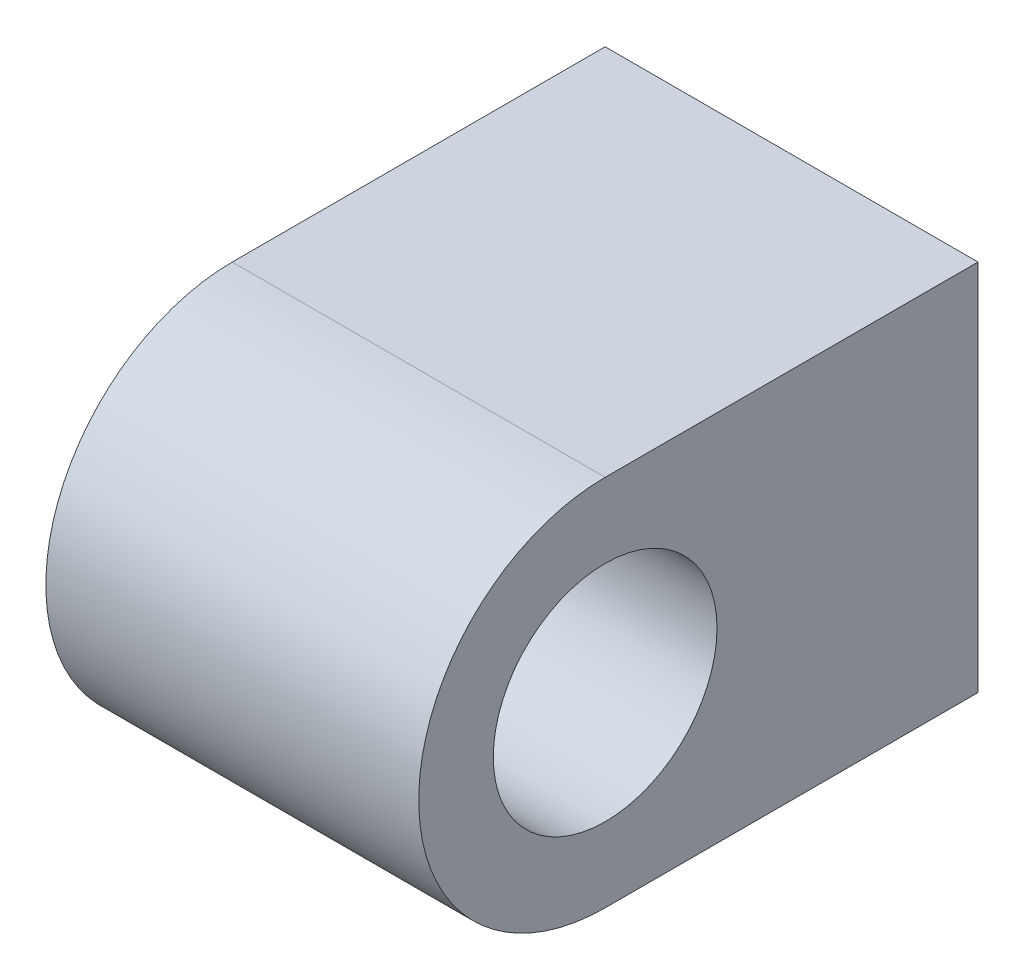
from build123d import *

# Parameters (mm, degrees)
ESQUISSE1_R        = 1.5
BOSS_EXTRU_1_DEPTH = 5


with BuildPart() as part:
    # Esquisse1 → Boss.-Extru.1 (new body)
    with BuildSketch(Plane(origin=(0, 0, 0), x_dir=(0, -1, 0), z_dir=(-1, 0, 0))):
        with BuildLine():
            Line((-5, 5), (-5, 0))
            Line((-5, 0), (0, 0))
            Line((0, 0), (0, 5))
            ThreePointArc((0, 5), (-2.5, 7.5), (-5, 5))
        make_face()
        with Locations(Location((-2.5, 5, 0), (0, 0, 270))):  # turned: the seam where the file's is
            Circle(ESQUISSE1_R, mode=Mode.SUBTRACT)
    extrude(amount=-BOSS_EXTRU_1_DEPTH)


solid = part.part
